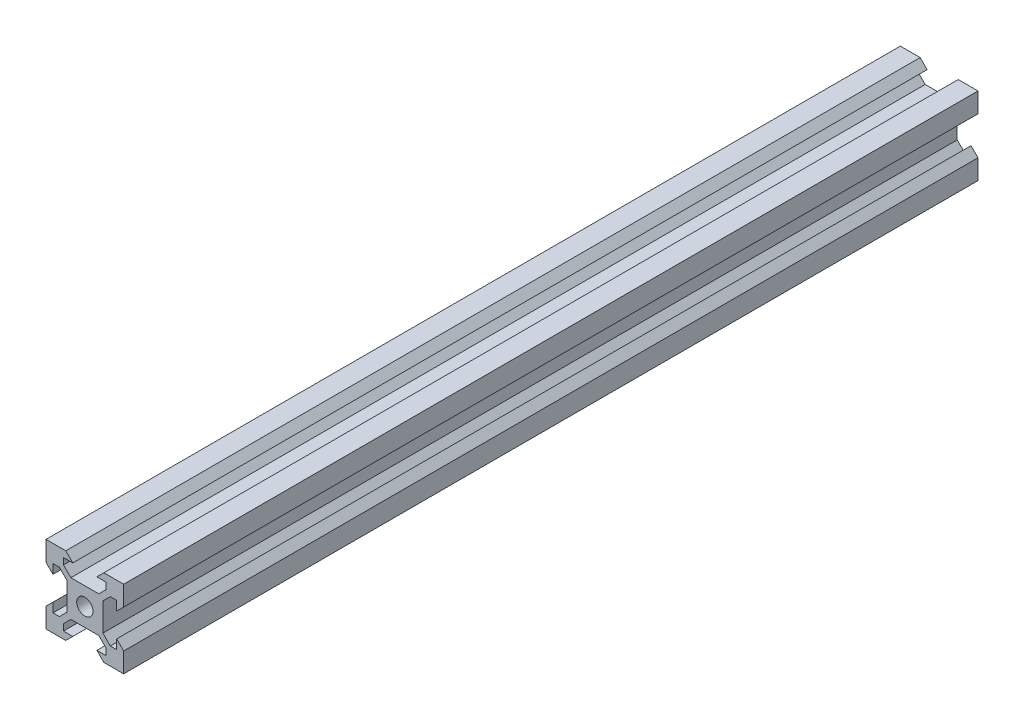
from build123d import *

# Parameters (mm, degrees)
SKETCH1_R           = 2.1
BOSS_EXTRUDE1_DEPTH = 110


with BuildPart() as part:
    # Sketch1 → Boss-Extrude1 (new body, symmetric)
    with BuildSketch(Plane.XY):
        Polygon((5.499339828, 6.56), (3.59, 4.650660172), (-3.59, 4.650660172), (-5.499339828, 6.56), (-5.499339828, 8.2), (-3.1, 8.2), (-4.9, 10), (-10, 10), (-10, 4.9), (-8.2, 3.1), (-8.2, 5.499339828), (-6.56, 5.499339828), (-4.650660172, 3.59), (-4.650660172, -3.59), (-6.56, -5.499339828), (-8.2, -5.499339828), (-8.2, -3.1), (-10, -4.9), (-10, -10), (-4.9, -10), (-3.1, -8.2), (-5.499339828, -8.2), (-5.499339828, -6.56), (-3.59, -4.650660172), (3.59, -4.650660172), (5.499339828, -6.56), (5.499339828, -8.2), (3.1, -8.2), (4.9, -10), (10, -10), (10, -4.9), (8.2, -3.1), (8.2, -5.499339828), (6.56, -5.499339828), (4.650660172, -3.59), (4.650660172, 3.59), (6.56, 5.499339828), (8.2, 5.499339828), (8.2, 3.1), (10, 4.9), (10, 10), (4.9, 10), (3.1, 8.2), (5.499339828, 8.2), align=None)
        Circle(SKETCH1_R, mode=Mode.SUBTRACT)
    extrude(amount=BOSS_EXTRUDE1_DEPTH, both=True)


solid = part.part
